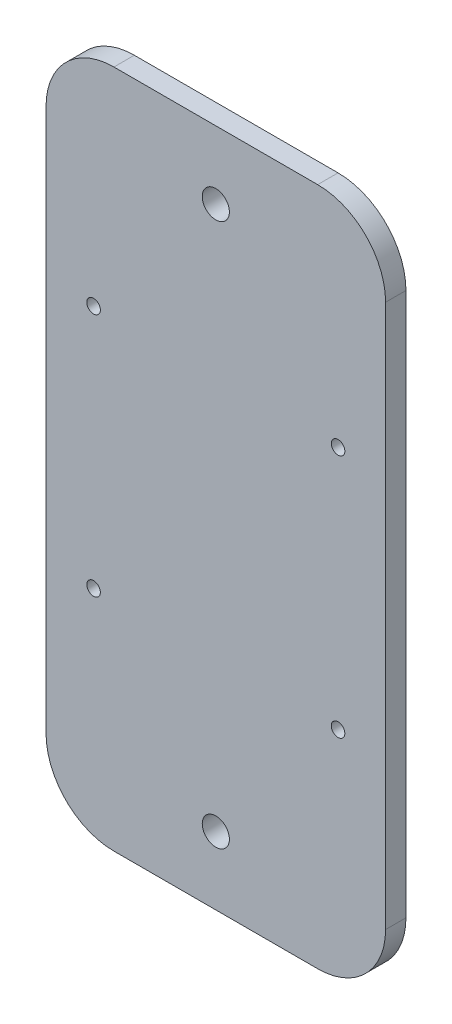
from build123d import *

# Parameters (mm, degrees)
ESQUISSE1_W             = 100
ESQUISSE1_H             = 200
BOSS_EXTRU_1_DEPTH      = 6
ESQUISSE2_R             = 2
ESQUISSE2_R_2           = 4
ENL_V_MAT_EXTRU_1_DEPTH = 6
CONG_1_R                = 20


with BuildPart() as part:
    # Esquisse1 → Boss.-Extru.1 (new body)
    with BuildSketch(Plane.XY):
        with Locations((-130.633802817, 58.529929577)):
            Rectangle(ESQUISSE1_W, ESQUISSE1_H)
    extrude(amount=BOSS_EXTRU_1_DEPTH)

    # Esquisse2 → Enlèv. mat.-Extru.1 (cut)
    with BuildSketch(Plane.XY.offset(6)):
        with Locations((-166.633802817, 94.529929577)):
            Circle(ESQUISSE2_R)
        with Locations((-166.633802817, 22.529929577)):
            Circle(ESQUISSE2_R)
        with Locations((-94.633802817, 22.529929577)):
            Circle(ESQUISSE2_R)
        with Locations((-94.633802817, 94.529929577)):
            Circle(ESQUISSE2_R)
        with Locations((-130.633802817, 138.529929577)):
            Circle(ESQUISSE2_R_2)
        with Locations((-130.633802817, -21.470070423)):
            Circle(ESQUISSE2_R_2)
    extrude(amount=-ENL_V_MAT_EXTRU_1_DEPTH, mode=Mode.SUBTRACT)

    # Congé1
    cong_1_edges = [part.edges().sort_by_distance(p)[0] for p in [
        (-180.633802817, 158.529929577, 3),
        (-80.633802817, 158.529929577, 3),
        (-80.633802817, -41.470070423, 3),
        (-180.633802817, -41.470070423, 3),
    ]]
    fillet(cong_1_edges, radius=CONG_1_R)


solid = part.part
